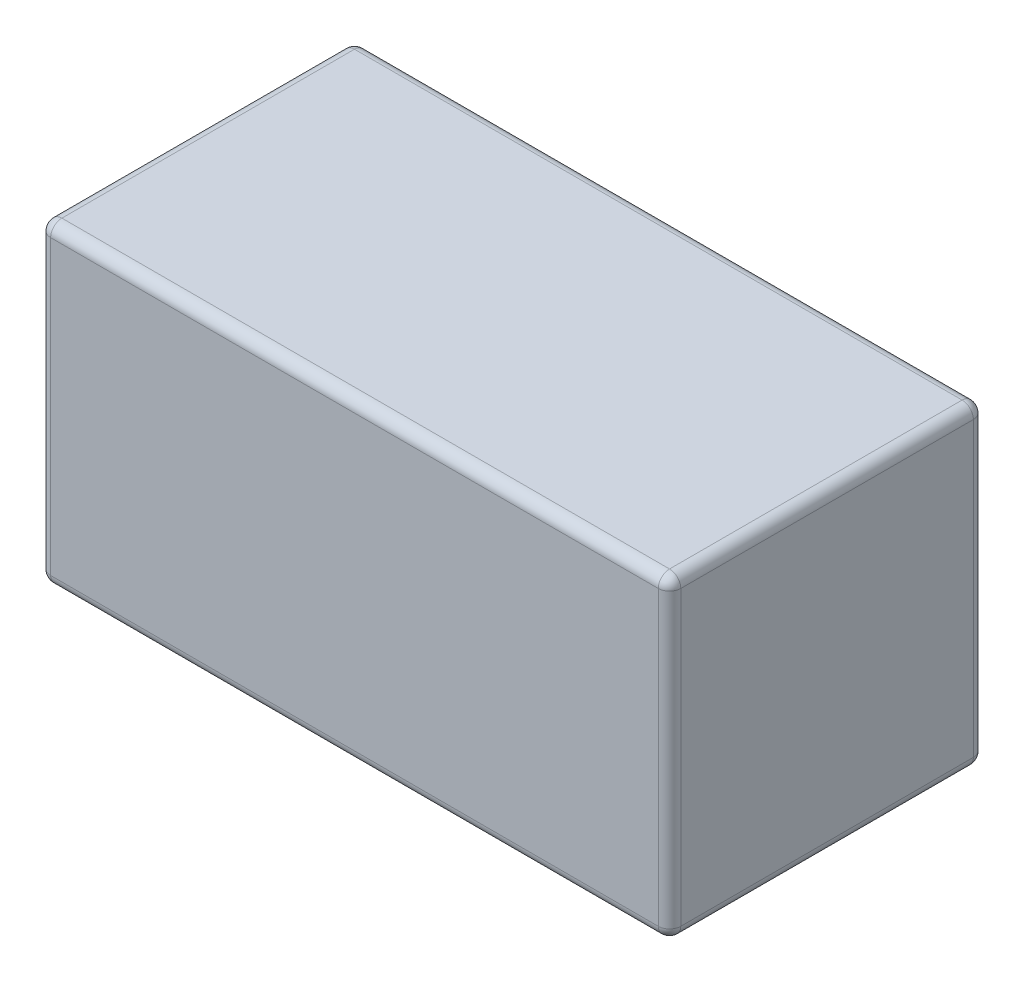
from build123d import *

# Parameters (mm, degrees)
SKETCH1_W           = 71.12
SKETCH1_H           = 35.56
BOSS_EXTRUDE1_DEPTH = 35.56
FILLET1_R           = 1.27


with BuildPart() as part:
    # Sketch1 → Boss-Extrude1 (new body)
    with BuildSketch(Plane(origin=(0, 0, 0), x_dir=(1, 0, 0), z_dir=(0, 1, 0))):
        with Locations((35.56, 17.78)):
            Rectangle(SKETCH1_W, SKETCH1_H)
    extrude(amount=BOSS_EXTRUDE1_DEPTH)

    # Fillet1
    fillet1_edges = [part.edges().sort_by_distance(p)[0] for p in [
        (71.12, 35.56, -17.78),
        (35.56, 35.56, -35.56),
        (0, 35.56, -17.78),
        (35.56, 0, -35.56),
        (71.12, 0, -17.78),
        (35.56, 0, 0),
        (0, 0, -17.78),
        (0, 17.78, -35.56),
        (71.12, 17.78, -35.56),
        (71.12, 17.78, 0),
        (0, 17.78, 0),
        (35.56, 35.56, 0),
    ]]
    fillet(fillet1_edges, radius=FILLET1_R)


solid = part.part
